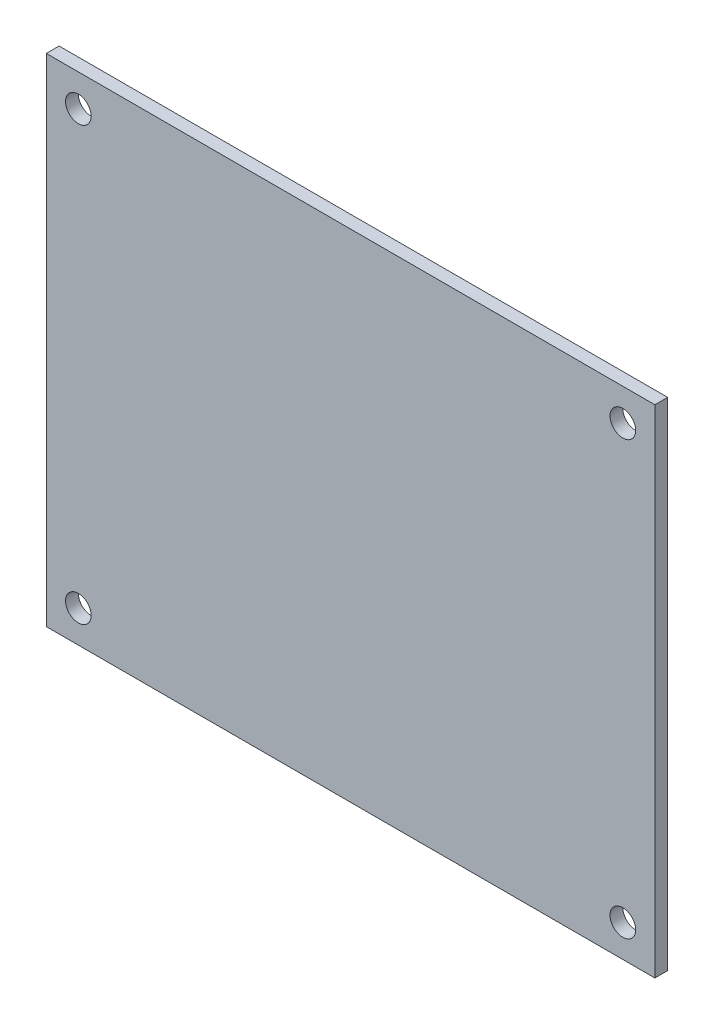
from build123d import *

# Parameters (mm, degrees)
SKETCH1_W  = 76
SKETCH1_H  = 62
SKETCH1_R  = 1.6
MAIN_DEPTH = 1.6


with BuildPart() as part:
    # Sketch1 → Main (new body)
    with BuildSketch(Plane.XY):
        Rectangle(SKETCH1_W, SKETCH1_H)
        with Locations((-34, 27)):
            Circle(SKETCH1_R, mode=Mode.SUBTRACT)
        with Locations((34, 27)):
            Circle(SKETCH1_R, mode=Mode.SUBTRACT)
        with Locations((34, -27)):
            Circle(SKETCH1_R, mode=Mode.SUBTRACT)
        with Locations((-34, -27)):
            Circle(SKETCH1_R, mode=Mode.SUBTRACT)
    extrude(amount=MAIN_DEPTH)


solid = part.part
